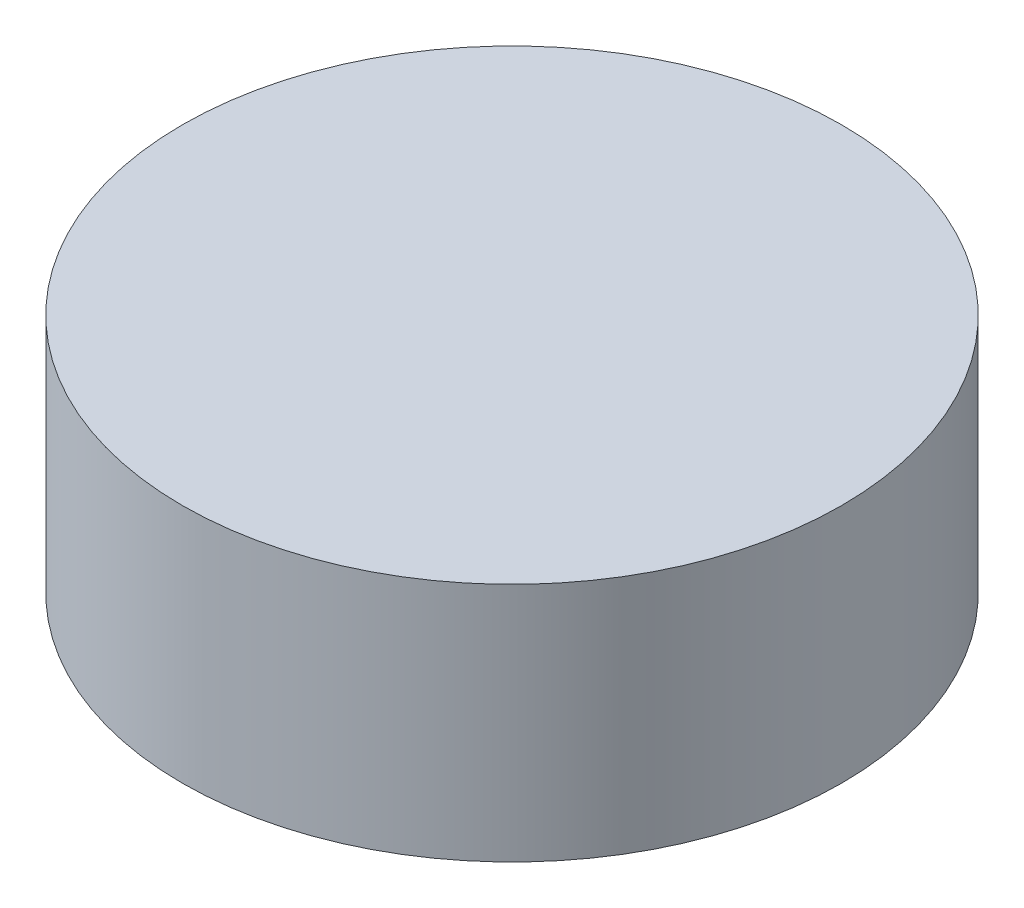
from build123d import *

# Parameters (mm, degrees)
SKETCH1_R      = 127.5
EXTRUDE1_DEPTH = 93


with BuildPart() as part:
    # Sketch1 → Extrude1 (new body)
    with BuildSketch(Plane(origin=(0, 0, 0), x_dir=(1, 0, 0), z_dir=(0, 1, 0))):
        with Locations(Location((0, 0, 0), (0, 0, 270))):  # turned: the seam where the file's is
            Circle(SKETCH1_R)
    extrude(amount=EXTRUDE1_DEPTH)


solid = part.part
